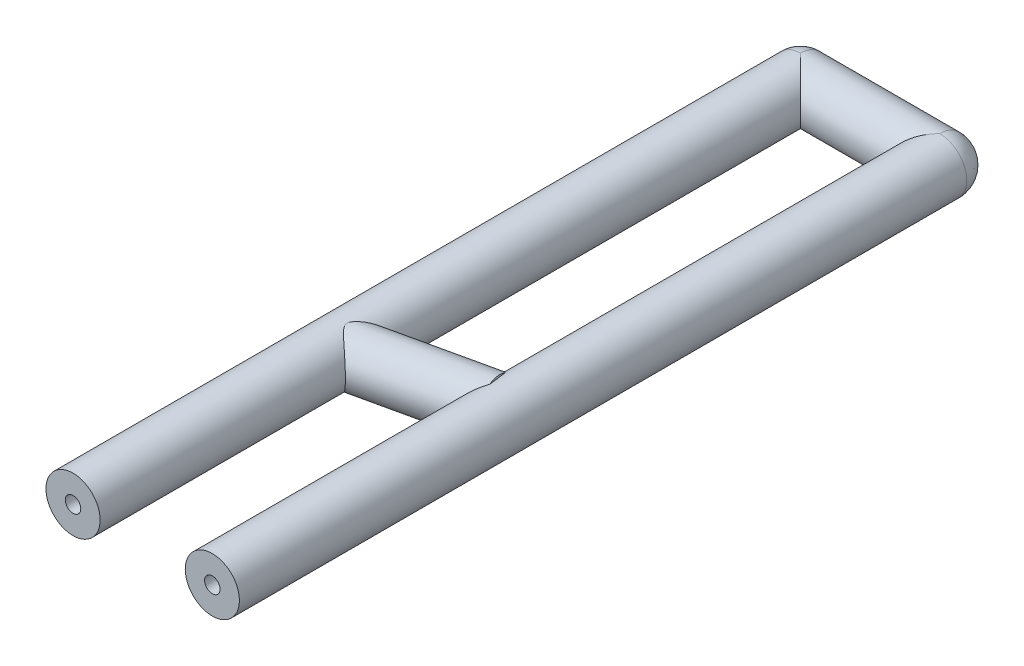
from build123d import *

# Parameters (mm, degrees)
SKETCH_5_W         = 1.75
SKETCH_5_H         = 47
SKETCH_6_W         = 1.75
SKETCH_6_H         = 47
SKETCH_7_W         = 9
SKETCH_7_H         = 1.75
LEFT_ORNER_ANGLE   = 90
RIGHT_CORNER_ANGLE = 90
SKETCH_11_R        = 0.5
SKETCH_13_R        = 0.5


with BuildPart() as part:
    # 草圖5 → left (revolve)
    with BuildSketch(Plane(origin=(0, 0, 0), x_dir=(1, 0, 0), z_dir=(0, 1, 0))):
        with Locations((-3.625, -23.5)):
            Rectangle(SKETCH_5_W, SKETCH_5_H)
    revolve(axis=Axis((-4.5, 0, 47), (0, 0, -1)))



with BuildPart() as body_2:
    # 草圖6 → right (revolve)
    with BuildSketch(Plane(origin=(0, 0, 0), x_dir=(1, 0, 0), z_dir=(0, 1, 0))):
        with Locations((5.375, -23.5)):
            Rectangle(SKETCH_6_W, SKETCH_6_H)
    revolve(axis=Axis((4.5, 0, 0), (0, 0, 1)))


with BuildPart() as part_1:
    add(part.part)

    add(body_2.part)  # down merges body 2
    # 草圖7 → down (revolve)
    with BuildSketch(Plane(origin=(0, 0, 0), x_dir=(1, 0, 0), z_dir=(0, 1, 0))):
        with Locations((0, 0.875)):
            Rectangle(SKETCH_7_W, SKETCH_7_H)
    revolve(axis=Axis((-4.5, 0, 0), (1, 0, 0)))

    # 草圖8 → left_orner (revolve)
    with BuildSketch(Plane(origin=(0, 0, 0), x_dir=(-1, 0, 0), z_dir=(0, 0, -1))):
        with BuildLine():
            Line((4.5, -1.75), (4.5, 1.75))
            ThreePointArc((4.5, 1.75), (6.25, 0), (4.5, -1.75))
        make_face()
    revolve(axis=Axis((-4.5, -1.75, 0), (0, -1, 0)), revolution_arc=LEFT_ORNER_ANGLE)

    # 草圖9 → right_corner (revolve)
    with BuildSketch(Plane(origin=(0, 0, 0), x_dir=(-1, 0, 0), z_dir=(0, 0, -1))):
        with BuildLine():
            Line((-4.5, -1.75), (-4.5, 1.75))
            ThreePointArc((-4.5, 1.75), (-6.25, 0), (-4.5, -1.75))
        make_face()
    revolve(axis=Axis((4.5, -1.75, 0), (0, 1, 0)), revolution_arc=RIGHT_CORNER_ANGLE)

    # 草圖10 → up (revolve)
    with BuildSketch(Plane(origin=(0, 0, 0), x_dir=(1, 0, 0), z_dir=(0, 1, 0))):
        Polygon((-4.131218222, -29.718048494), (-4.131218222, -31.459518002), (4.131218222, -29.623421015), (4.131218222, -27.881951506), align=None)
    revolve(axis=Axis((-4.5, 0, 29.8), (0.97618706, 0, -0.216930458)))

    # inside: sweep along a path in 草圖12
    with BuildLine(Plane(origin=(0, 0, 0), x_dir=(1, 0, 0), z_dir=(0, 1, 0))) as inside_path:
        Line((-4.5, -47), (-4.5, -1))
        ThreePointArc((-4.5, -1), (-4.207106781, -0.292893219), (-3.5, 0))
        Line((-3.5, 0), (3.5, 0))
        ThreePointArc((3.5, 0), (4.207106781, -0.292893219), (4.5, -1))
        Line((4.5, -1), (4.5, -47))
    # 草圖11 → inside (sweep, cut)
    with BuildSketch(Plane.XY.offset(47)):
        with Locations((-4.5, 0)):
            Circle(SKETCH_11_R)
    sweep(path=inside_path.line, mode=Mode.SUBTRACT)

    # up_inside: sweep along a path in 草圖14
    with BuildLine(Plane(origin=(0, 0, 0), x_dir=(1, 0, 0), z_dir=(0, 1, 0))) as up_inside_path:
        Line((4.5, -27.8), (-4.5, -29.8))
    # 草圖13 → up_inside (sweep, cut)
    with BuildSketch(Plane(origin=(4.5, 0, 0), x_dir=(0, 0, -1), z_dir=(1, 0, 0))):
        with Locations((-27.8, 0)):
            Circle(SKETCH_13_R)
    sweep(path=up_inside_path.line, mode=Mode.SUBTRACT)


solid = part_1.part
